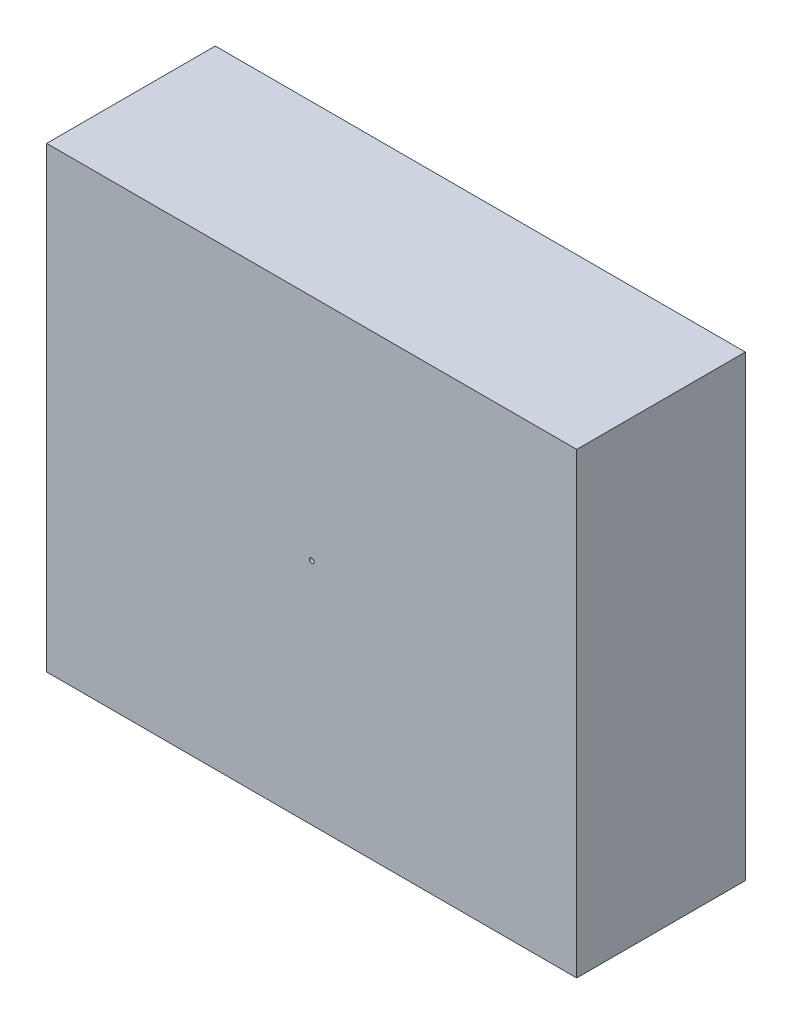
from build123d import *

# Parameters (mm, degrees)
ESQUISSE1_W                  = 220
ESQUISSE1_H                  = 190
BOSS_EXTRU_1_DEPTH           = 70
ESQUISSE2_R                  = 1
ENL_V_MAT_EXTRU_1_DEPTH      = 10
ENL_V_MAT_EXTRU_1_DEPTH_BACK = 119


with BuildPart() as part:
    # Esquisse1 → Boss.-Extru.1 (new body)
    with BuildSketch(Plane.XY):
        with Locations((-110, 95)):
            Rectangle(ESQUISSE1_W, ESQUISSE1_H)
    extrude(amount=BOSS_EXTRU_1_DEPTH)

    # Esquisse2 → Enlèv. mat.-Extru.1 (cut, two sides)
    with BuildSketch(Plane(origin=(0, 0, 0), x_dir=(-1, 0, 0), z_dir=(0, 0, -1))) as enl_v_mat_extru_1_sk:
        with Locations((110, 95)):
            Circle(ESQUISSE2_R)
    extrude(amount=ENL_V_MAT_EXTRU_1_DEPTH, mode=Mode.SUBTRACT)
    extrude(enl_v_mat_extru_1_sk.sketch, amount=-ENL_V_MAT_EXTRU_1_DEPTH_BACK, mode=Mode.SUBTRACT)


solid = part.part
